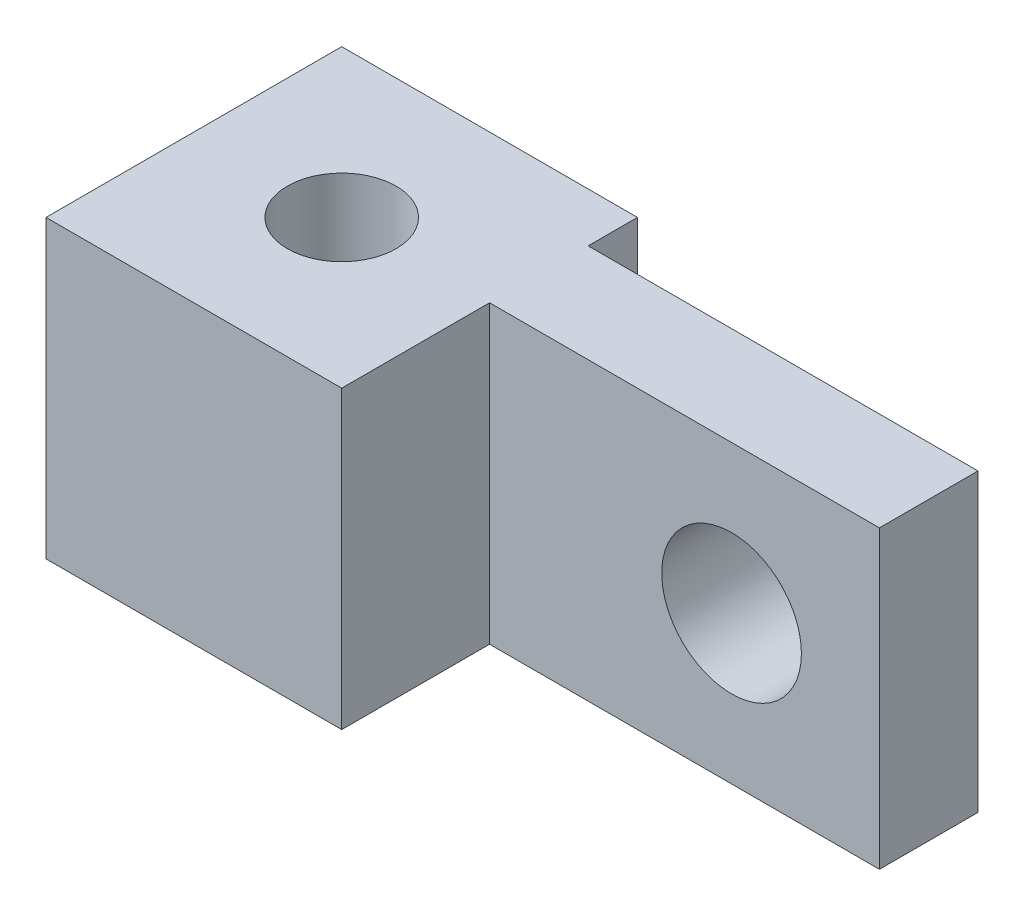
from build123d import *

# Parameters (mm, degrees)
SKETCH1_W                 = 44.1625
SKETCH1_H                 = 19.05
BOSS_EXTRUDE1_DEPTH       = 6.35
SKETCH2_W                 = 19.05
SKETCH2_H                 = 19.05
BOSS_EXTRUDE2_DEPTH       = 9.525
M8X1_0_TAPPED_HOLE1_D     = 7
M8X1_0_TAPPED_HOLE1_DEPTH = 21.082
M8X1_0_TAPPED_HOLE1_TIP   = 2.103012167
M8_CLEARANCE_HOLE1_D      = 9
M8_CLEARANCE_HOLE1_DEPTH  = 21.082
M8_CLEARANCE_HOLE1_TIP    = 2.703872786


with BuildPart() as part:
    # Sketch1 → Boss-Extrude1 (new body)
    with BuildSketch(Plane.XY):
        with Locations((38.24375, 204.55)):
            Rectangle(SKETCH1_W, SKETCH1_H)
    extrude(amount=BOSS_EXTRUDE1_DEPTH)

    # Sketch2 → Boss-Extrude2 (add, symmetric)
    with BuildSketch(Plane.XY.offset(6.35)):
        with Locations((25.6875, 204.55)):
            Rectangle(SKETCH2_W, SKETCH2_H)
    extrude(amount=BOSS_EXTRUDE2_DEPTH, both=True)

    # M8x1.0 Tapped Hole1
    with Locations(Plane(origin=(0, 214.075, 0), x_dir=(1, 0, 0), z_dir=(0, 1, 0))):
        with Locations((25.6875, -6.35)):
            Hole(M8X1_0_TAPPED_HOLE1_D / 2, depth=M8X1_0_TAPPED_HOLE1_DEPTH)
            with Locations((0, 0, -(M8X1_0_TAPPED_HOLE1_DEPTH + M8X1_0_TAPPED_HOLE1_TIP / 2))):  # 118° drill point
                Cone(0, M8X1_0_TAPPED_HOLE1_D / 2, M8X1_0_TAPPED_HOLE1_TIP, mode=Mode.SUBTRACT)

    # M8 Clearance Hole1
    with Locations(Plane.XY.offset(6.35)):
        with Locations((50.8, 204.55)):
            Hole(M8_CLEARANCE_HOLE1_D / 2, depth=M8_CLEARANCE_HOLE1_DEPTH)
            with Locations((0, 0, -(M8_CLEARANCE_HOLE1_DEPTH + M8_CLEARANCE_HOLE1_TIP / 2))):  # 118° drill point
                Cone(0, M8_CLEARANCE_HOLE1_D / 2, M8_CLEARANCE_HOLE1_TIP, mode=Mode.SUBTRACT)


solid = part.part
